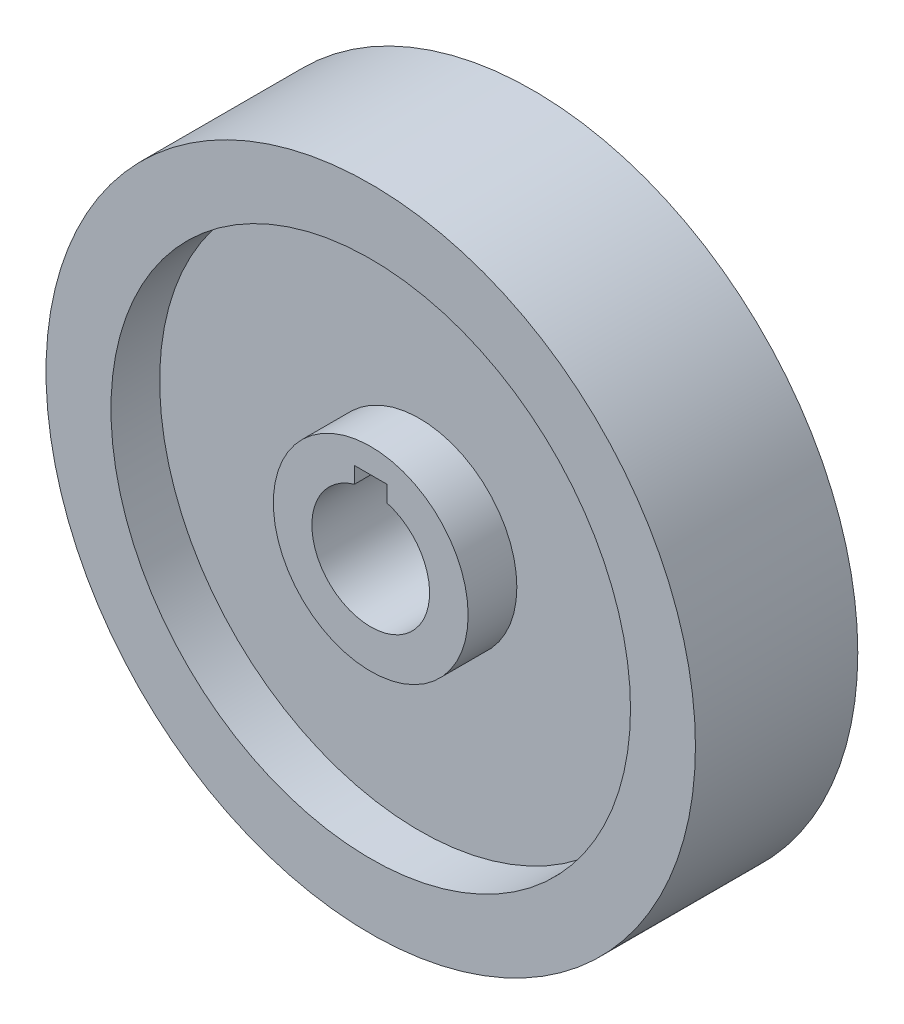
from build123d import *

# Parameters (mm, degrees)
SKETCH4_W          = 6.35
SKETCH4_H          = 3.175
CUT_EXTRUDE1_DEPTH = 32.75


with BuildPart() as part:
    # Sketch1 → Revolve1 (revolve)
    with BuildSketch(Plane(origin=(0, 0, 0), x_dir=(0, 0, -1), z_dir=(1, 0, 0))):
        Polygon((15.875, 11.509375), (-15.875, 11.509375), (-15.875, 19.05), (-6.35, 19.05), (-6.35, 50.8), (-15.875, 50.8), (-15.875, 63.5), (15.875, 63.5), (15.875, 50.8), (6.35, 50.8), (6.35, 19.05), (15.875, 19.05), align=None)
    revolve(axis=Axis((0, 0, 34.214514903), (0, 0, -1)))

    # Sketch4 → Cut-Extrude1 (cut, through all)
    with BuildSketch(Plane(origin=(0, 0, -15.875), x_dir=(-1, 0, 0), z_dir=(0, 0, -1))):
        with Locations((0, 12.650279393)):
            Rectangle(SKETCH4_W, SKETCH4_H)
    extrude(amount=-CUT_EXTRUDE1_DEPTH, mode=Mode.SUBTRACT)


solid = part.part
